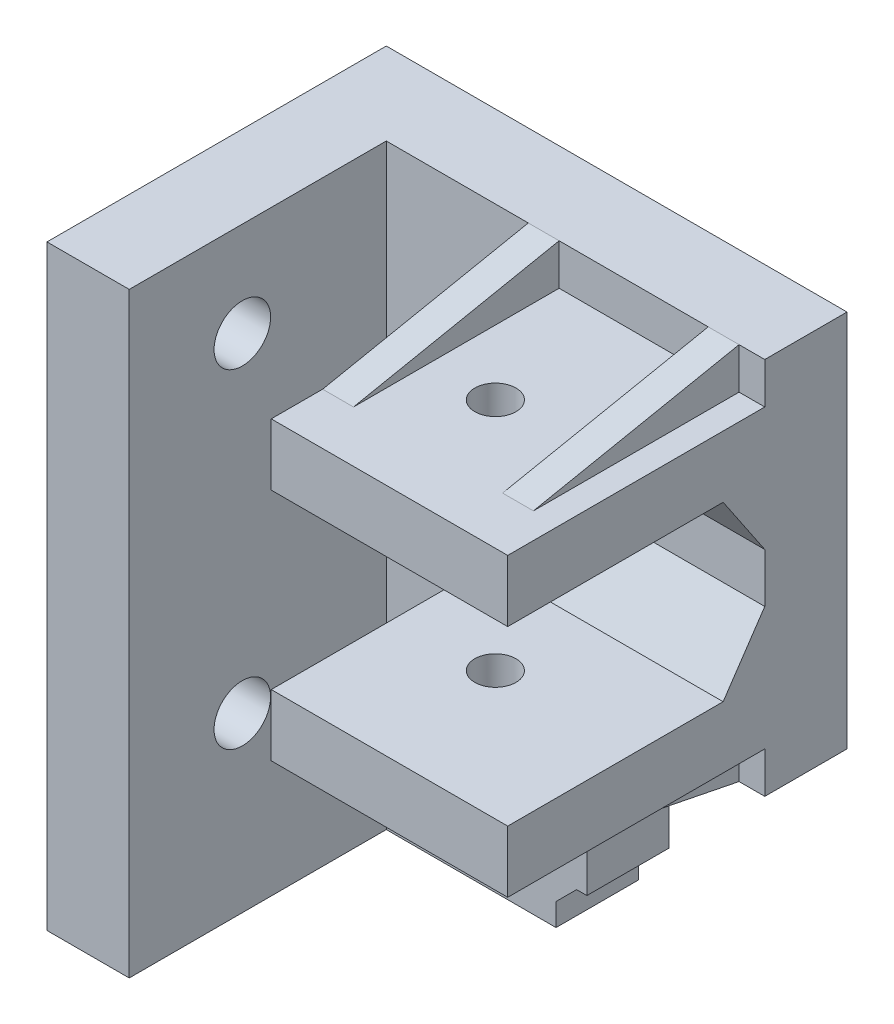
from build123d import *

# Parameters (mm, degrees)
SKETCH1_W               = 24.51
SKETCH1_H               = 148
BOSS_EXTRUDE1_DEPTH     = 8
SKETCH2_W               = 8
SKETCH2_H               = 148
BOSS_EXTRUDE2_DEPTH     = 25
SKETCH4_W               = 20.3
SKETCH4_H               = 36.8
BOSS_EXTRUDE3_DEPTH     = 8
SKETCH5_W               = 23
SKETCH5_H               = 6
BOSS_EXTRUDE4_DEPTH     = 25
CUT_EXTRUDE2_REACH      = 151.752
SKETCH6_R               = 2
RIB1_REACH              = 159.03
SKETCH8_WALL_W          = 336.456302216
SKETCH8_WALL_H          = 3
MIRROR2_COPY_1_REACH    = 159.03
MIRROR2_COPY_1_SKETCH_W = 336.456302216
MIRROR2_COPY_1_SKETCH_H = 3
SKETCH3_R               = 2.5
CUT_EXTRUDE1_DEPTH      = 10
SKETCH12_R              = 2.75
CUT_EXTRUDE3_DEPTH      = 8
SKETCH13_W              = 5
SKETCH13_H              = 46
BOSS_EXTRUDE5_DEPTH     = 8
SKETCH14_W              = 3
SKETCH14_H              = 17
BOSS_EXTRUDE6_DEPTH     = 8
CHAMFER1_SIZE           = 2
CHAMFER2_SIZE           = 6
CHAMFER2_SIZE2          = 4.047051101
SKETCH15_W              = 33
SKETCH15_H              = 90
CUT_EXTRUDE4_DEPTH      = 48


with BuildPart() as part:
    # Sketch1 → Boss-Extrude1 (new body)
    with BuildSketch(Plane.XY):
        with Locations((-12.255, 74)):
            Rectangle(SKETCH1_W, SKETCH1_H)
    extrude(amount=BOSS_EXTRUDE1_DEPTH)

    # Sketch2 → Boss-Extrude2 (add)
    with BuildSketch(Plane.XY.offset(8)):
        with Locations((-20.51, 74)):
            Rectangle(SKETCH2_W, SKETCH2_H)
    extrude(amount=BOSS_EXTRUDE2_DEPTH)

    # Sketch4 → Boss-Extrude3 (add)
    with BuildSketch(Plane(origin=(0, 0, 0), x_dir=(-1, 0, 0), z_dir=(0, 0, -1))):
        with Locations((-10.15, 129.6)):
            Rectangle(SKETCH4_W, SKETCH4_H)
    extrude(amount=-BOSS_EXTRUDE3_DEPTH)

    # Sketch5 → Boss-Extrude4 (add)
    with BuildSketch(Plane.XY.offset(8)):
        with Locations((8.8, 118.2)):
            Rectangle(SKETCH5_W, SKETCH5_H)
        with Locations((8.8, 141)):
            Rectangle(SKETCH5_W, SKETCH5_H)
    extrude(amount=BOSS_EXTRUDE4_DEPTH)

    # Cut-Extrude2: up to this face of the body (flat: up to its plane)
    cut_extrude2_end = Plane(part.part.faces().sort_by_distance((8.8, 115.2, 20.5))[0])
    # Sketch6 → Cut-Extrude2 (cut, up to the picked face)
    with BuildSketch(Plane(origin=(0, 144, 0), x_dir=(1, 0, 0), z_dir=(0, 1, 0)), mode=Mode.PRIVATE) as cut_extrude2_sk1:
        with Locations(Location((6.6, -20.5, 0), (0, 0, 270))):
            Circle(SKETCH6_R)
    cut_extrude2_tool1 = split(extrude(cut_extrude2_sk1.sketch, amount=-CUT_EXTRUDE2_REACH, mode=Mode.PRIVATE), bisect_by=cut_extrude2_end, keep=Keep.BOTH, mode=Mode.PRIVATE)
    add(cut_extrude2_tool1.solids().sort_by(Axis((6.6, 144, 20.5), (0, -1, 0)))[0], mode=Mode.SUBTRACT)

    # Sketch8 wall → Rib1 (add, up to next)
    with BuildSketch(Plane(origin=(16.3, 146, 18), x_dir=(0, -0.196116135138, 0.980580675691), z_dir=(0, -0.980580675691, -0.196116135138)), mode=Mode.PRIVATE) as rib1_sk1:
        Rectangle(SKETCH8_WALL_W, SKETCH8_WALL_H)
    rib1_tool1 = extrude(rib1_sk1.sketch, amount=RIB1_REACH, mode=Mode.PRIVATE) - part.part
    rib1 = rib1_tool1.solids().sort_by_distance((16.3, 146, 18))[0]
    add(rib1)

    # Mirror1: Rib1 across plane
    add(rib1.mirror(Plane.ZX.offset(129.6)))

    # Mirror2: Rib1 across plane
    add(rib1.mirror(Plane.ZY.offset(-7.55)))

    # Mirror2 copy 1 sketch → Mirror2 copy 1 (add, up to next)
    with BuildSketch(Plane(origin=(-1.2, 113.2, 18), x_dir=(0, 0.196116135138, 0.980580675691), z_dir=(0, 0.980580675691, -0.196116135138)), mode=Mode.PRIVATE) as mirror2_copy_1_sk1:
        Rectangle(MIRROR2_COPY_1_SKETCH_W, MIRROR2_COPY_1_SKETCH_H)
    mirror2_copy_1_tool1 = extrude(mirror2_copy_1_sk1.sketch, amount=MIRROR2_COPY_1_REACH, mode=Mode.PRIVATE) - part.part
    add(mirror2_copy_1_tool1.solids().sort_by_distance((-1.2, 113.2, 18))[0])

    # Sketch3 → Cut-Extrude1 (cut)
    with BuildSketch(Plane.XY.offset(8)):
        with Locations((-8, 8)):
            Circle(SKETCH3_R)
        with Locations((-8, 40)):
            Circle(SKETCH3_R)
        with Locations((-8, 100)):
            Circle(SKETCH3_R)
        with Locations((-8, 132)):
            Circle(SKETCH3_R)
    extrude(amount=-CUT_EXTRUDE1_DEPTH, mode=Mode.SUBTRACT)

    # Sketch12 → Cut-Extrude3 (cut)
    with BuildSketch(Plane.ZY.offset(24.51)):
        with Locations((22, 138.8)):
            Circle(SKETCH12_R)
        with Locations((22, 106.8)):
            Circle(SKETCH12_R)
        with Locations((22, 41.7)):
            Circle(SKETCH12_R)
        with Locations((22, 9.7)):
            Circle(SKETCH12_R)
    extrude(amount=-CUT_EXTRUDE3_DEPTH, mode=Mode.SUBTRACT)

    # Sketch13 → Boss-Extrude5 (add)
    with BuildSketch(Plane(origin=(0, 0, 0), x_dir=(-1, 0, 0), z_dir=(0, 0, -1))):
        with Locations((-2.5, 23)):
            Rectangle(SKETCH13_W, SKETCH13_H)
    extrude(amount=-BOSS_EXTRUDE5_DEPTH)

    # Sketch14 → Boss-Extrude6 (add)
    with BuildSketch(Plane(origin=(0, 0, 0), x_dir=(-1, 0, 0), z_dir=(0, 0, -1))):
        with Locations((-1.5, 102.7)):
            Rectangle(SKETCH14_W, SKETCH14_H)
    extrude(amount=-BOSS_EXTRUDE6_DEPTH)

    # Chamfer1
    chamfer1_edges = [part.edges().sort_by_distance(p)[0] for p in [
        (0, 46, 4),
        (3, 111.2, 4),
        (0, 94.2, 4),
    ]]
    chamfer(chamfer1_edges, length=CHAMFER1_SIZE)

    # Chamfer2
    chamfer2_edges = [part.edges().sort_by_distance(p)[0] for p in [
        (8.8, 121.2, 8),
        (8.8, 138, 8),
    ]]
    chamfer2_side = [part.faces().sort_by_distance(p)[0] for p in [
        (-4.974591741, 76.782250606, 8),
    ]]
    chamfer(chamfer2_edges, length=CHAMFER2_SIZE, length2=CHAMFER2_SIZE2, reference=chamfer2_side[0])

    # Sketch15 → Cut-Extrude4 (cut)
    with BuildSketch(Plane(origin=(20.3, 0, 0), x_dir=(0, 0, -1), z_dir=(1, 0, 0))):
        with Locations((-16.5, 45)):
            Rectangle(SKETCH15_W, SKETCH15_H)
    extrude(amount=-CUT_EXTRUDE4_DEPTH, mode=Mode.SUBTRACT)


solid = part.part
